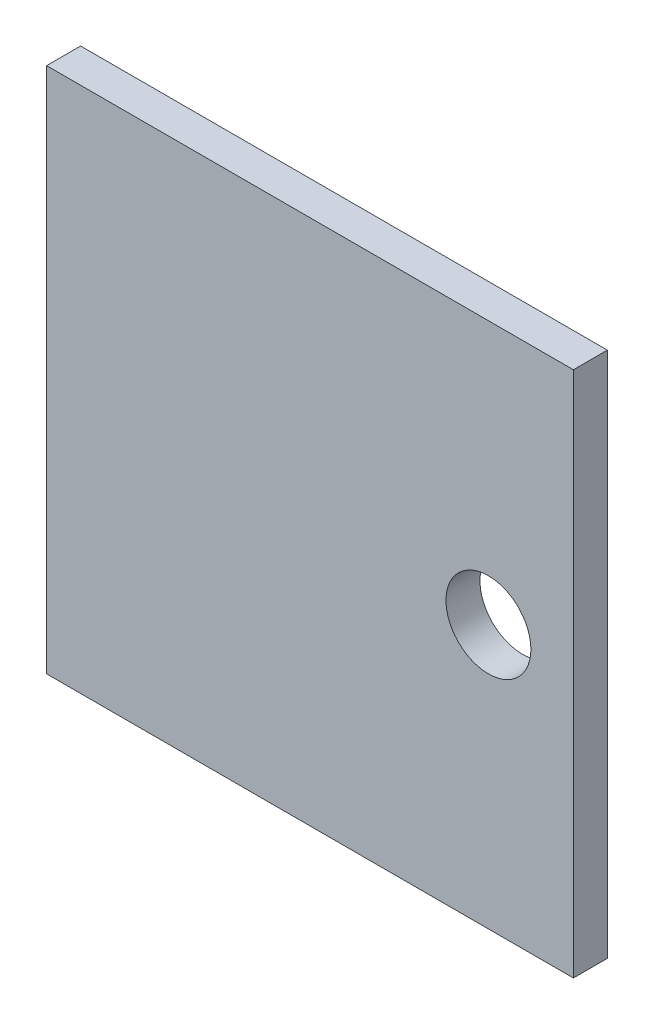
from build123d import *

# Parameters (mm, degrees)
SKETCH1_W           = 62
SKETCH1_H           = 62
SKETCH1_R           = 5
BOSS_EXTRUDE1_DEPTH = 4


with BuildPart() as part:
    # Sketch1 → Boss-Extrude1 (new body)
    with BuildSketch(Plane.XY):
        Rectangle(SKETCH1_W, SKETCH1_H)
        with Locations((21, 0)):
            Circle(SKETCH1_R, mode=Mode.SUBTRACT)
    extrude(amount=BOSS_EXTRUDE1_DEPTH)


solid = part.part
